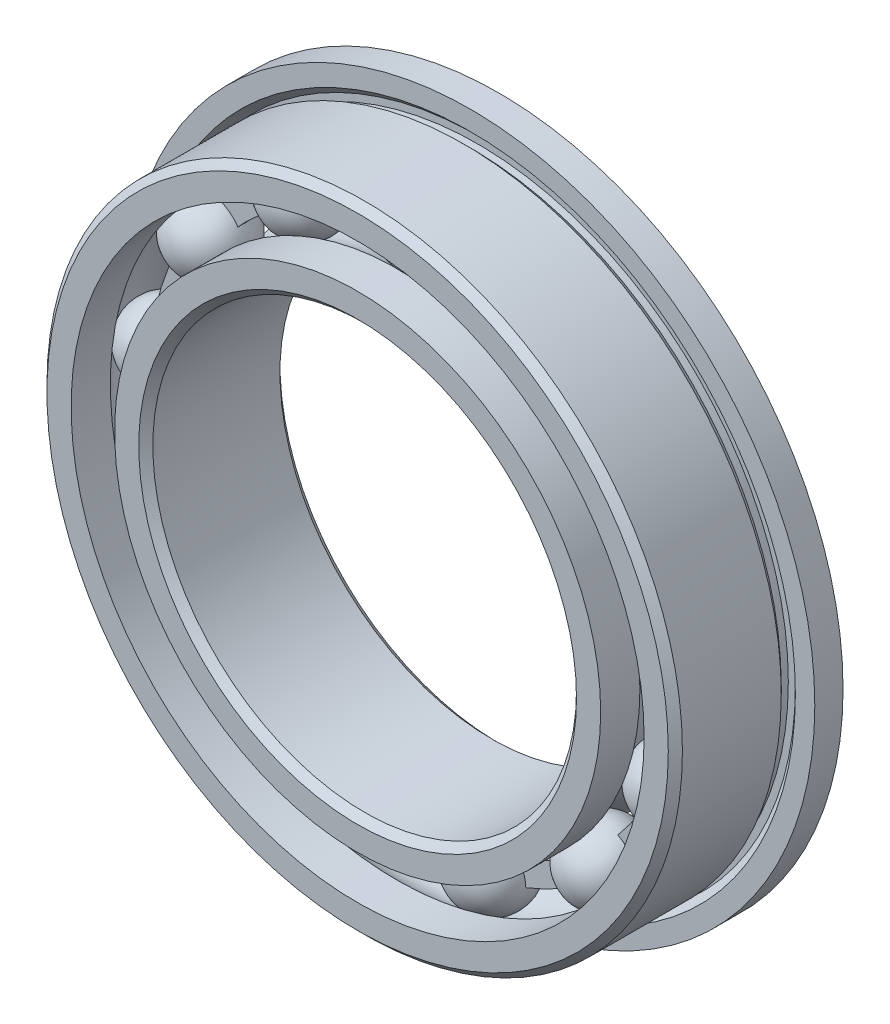
from build123d import *

# Parameters (mm, degrees)
SKETCH6_W         = 0.205128206
SKETCH6_H         = 0.615384616
CIRPATTERN1_COUNT = 13


with BuildPart() as part:
    # Sketch1 → Revolve1 (revolve)
    with BuildSketch(Plane(origin=(0, 0, 0), x_dir=(0, 0, -1), z_dir=(1, 0, 0))):
        with BuildLine():
            Line((-1.8, 9), (-2, 8.8))
            Line((-2, 8.8), (-2, 8.115384615))
            Line((-2, 8.115384615), (-0.888888889, 8.115384615))
            ThreePointArc((-0.888888889, 8.115384615), (0, 8.581120568), (0.888888889, 8.115384615))
            Line((0.888888889, 8.115384615), (2, 8.115384615))
            Line((2, 8.115384615), (2, 8.8))
            Line((2, 8.8), (2, 9.75))
            Line((2, 9.75), (1.2, 9.75))
            Line((1.2, 9.75), (1.2, 9.2))
            Line((1.2, 9.2), (1.4, 9))
            Line((1.4, 9), (1.4, 8.8))
            Line((1.4, 8.8), (1.2, 8.8))
            Line((1.2, 8.8), (1, 9))
            Line((1, 9), (-1.8, 9))
        make_face()
    revolve(axis=Axis((0, 0, 2), (0, 0, -1)))


with BuildPart() as body_2:
    # Sketch3 → Revolve3 (revolve)
    with BuildSketch(Plane(origin=(0, 0, 0), x_dir=(0, 0, -1), z_dir=(1, 0, 0))):
        with BuildLine():
            Line((-2, 6.884615385), (-0.888888889, 6.884615385))
            ThreePointArc((-0.888888889, 6.884615385), (0, 6.418879432), (0.888888889, 6.884615385))
            Line((0.888888889, 6.884615385), (2, 6.884615385))
            Line((2, 6.884615385), (2, 6.2))
            Line((2, 6.2), (1.8, 6))
            Line((1.8, 6), (-1.8, 6))
            Line((-1.8, 6), (-2, 6.2))
            Line((-2, 6.2), (-2, 6.884615385))
        make_face()
    revolve(axis=Axis((0, 0, 2), (0, 0, -1)))


with BuildPart() as body_3:
    # Sketch6 → Revolve6 (revolve)
    with BuildSketch(Plane(origin=(0, 0, 0), x_dir=(0, 0, -1), z_dir=(1, 0, 0))):
        with Locations((0, 7.5)):
            Rectangle(SKETCH6_W, SKETCH6_H)
    revolve(axis=Axis((0, 0, 2), (0, 0, -1)))


with BuildPart() as body_4:
    # Sketch4 → Revolve4 (revolve)
    with BuildSketch(Plane(origin=(0, 0, 0), x_dir=(0, 0, -1), z_dir=(1, 0, 0))):
        with BuildLine():
            Line((-1.081120568, 7.5), (1.081120568, 7.5))
            ThreePointArc((1.081120568, 7.5), (0, 8.581120568), (-1.081120568, 7.5))
        make_face()
    revolve(axis=Axis((0, 7.5, 1.081120568), (0, 0, -1)))


with BuildPart() as cirpattern1_1:
    # CirPattern1: pattern copy
    add(body_4.part.rotate(Axis((0, 0, -2), (0, 0, 1)), 1 * 360 / CIRPATTERN1_COUNT))


with BuildPart() as cirpattern1_2:
    # CirPattern1: pattern copy
    add(body_4.part.rotate(Axis((0, 0, -2), (0, 0, 1)), 2 * 360 / CIRPATTERN1_COUNT))


with BuildPart() as cirpattern1_3:
    # CirPattern1: pattern copy
    add(body_4.part.rotate(Axis((0, 0, -2), (0, 0, 1)), 3 * 360 / CIRPATTERN1_COUNT))


with BuildPart() as cirpattern1_4:
    # CirPattern1: pattern copy
    add(body_4.part.rotate(Axis((0, 0, -2), (0, 0, 1)), 4 * 360 / CIRPATTERN1_COUNT))


with BuildPart() as cirpattern1_5:
    # CirPattern1: pattern copy
    add(body_4.part.rotate(Axis((0, 0, -2), (0, 0, 1)), 5 * 360 / CIRPATTERN1_COUNT))


with BuildPart() as cirpattern1_6:
    # CirPattern1: pattern copy
    add(body_4.part.rotate(Axis((0, 0, -2), (0, 0, 1)), 6 * 360 / CIRPATTERN1_COUNT))


with BuildPart() as cirpattern1_7:
    # CirPattern1: pattern copy
    add(body_4.part.rotate(Axis((0, 0, -2), (0, 0, 1)), 7 * 360 / CIRPATTERN1_COUNT))


with BuildPart() as cirpattern1_8:
    # CirPattern1: pattern copy
    add(body_4.part.rotate(Axis((0, 0, -2), (0, 0, 1)), 8 * 360 / CIRPATTERN1_COUNT))


with BuildPart() as cirpattern1_9:
    # CirPattern1: pattern copy
    add(body_4.part.rotate(Axis((0, 0, -2), (0, 0, 1)), 9 * 360 / CIRPATTERN1_COUNT))


with BuildPart() as cirpattern1_10:
    # CirPattern1: pattern copy
    add(body_4.part.rotate(Axis((0, 0, -2), (0, 0, 1)), 10 * 360 / CIRPATTERN1_COUNT))


with BuildPart() as cirpattern1_11:
    # CirPattern1: pattern copy
    add(body_4.part.rotate(Axis((0, 0, -2), (0, 0, 1)), 11 * 360 / CIRPATTERN1_COUNT))


with BuildPart() as cirpattern1_12:
    # CirPattern1: pattern copy
    add(body_4.part.rotate(Axis((0, 0, -2), (0, 0, 1)), 12 * 360 / CIRPATTERN1_COUNT))


solid = Compound([part.part, body_2.part, body_3.part, body_4.part, cirpattern1_1.part, cirpattern1_2.part, cirpattern1_3.part, cirpattern1_4.part, cirpattern1_5.part, cirpattern1_6.part, cirpattern1_7.part, cirpattern1_8.part, cirpattern1_9.part, cirpattern1_10.part, cirpattern1_11.part, cirpattern1_12.part])
